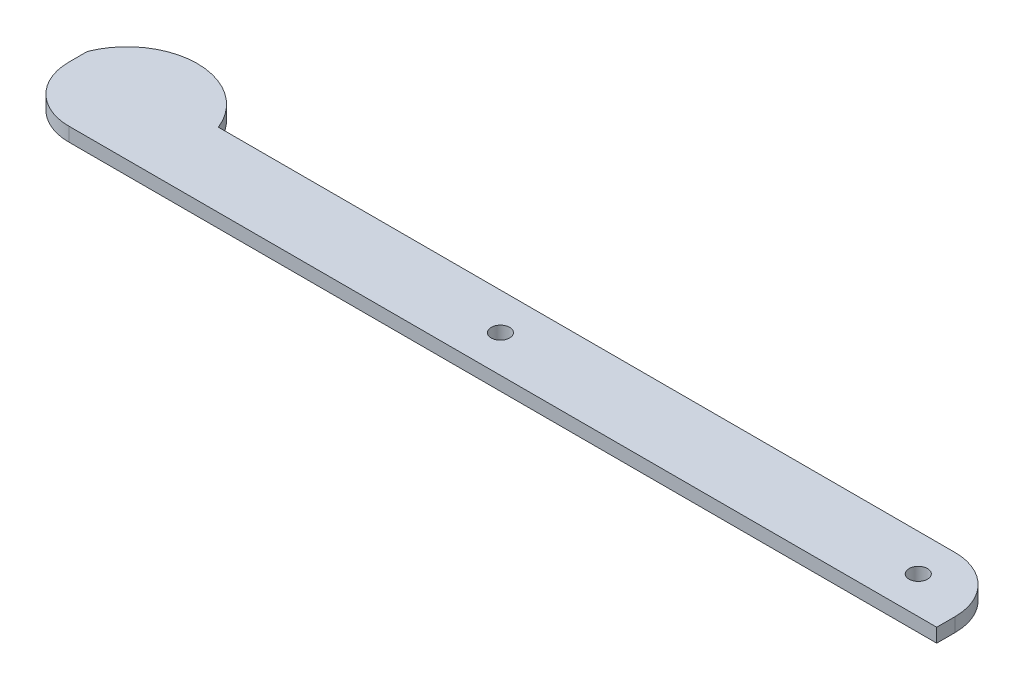
from build123d import *

# Parameters (mm, degrees)
SKETCH1_R           = 12.7
BOSS_EXTRUDE1_DEPTH = 19.05


with BuildPart() as part:
    # Sketch1 → Boss-Extrude1 (new body)
    with BuildSketch(Plane(origin=(0, 0, 0), x_dir=(1, 0, 0), z_dir=(0, 1, 0))):
        with BuildLine():
            Line((-558.8, -50.8), (635, -50.8))
            Line((635, -50.8), (635, -25.4))
            ThreePointArc((635, -25.4), (612.681536726, 28.481536726), (558.8, 50.8))
            Line((558.8, 50.8), (-454.65655736, 50.8))
            ThreePointArc((-454.65655736, 50.8), (-544.82827868, 112.124515873), (-635, 50.8))
            Line((-635, 50.8), (-635, 25.4))
            ThreePointArc((-635, 25.4), (-612.681536726, -28.481536726), (-558.8, -50.8))
        make_face()
        with Locations((-15.94, 0)):
            Circle(SKETCH1_R, mode=Mode.SUBTRACT)
        with Locations((558.8, 0)):
            Circle(SKETCH1_R, mode=Mode.SUBTRACT)
    extrude(amount=BOSS_EXTRUDE1_DEPTH)


solid = part.part
